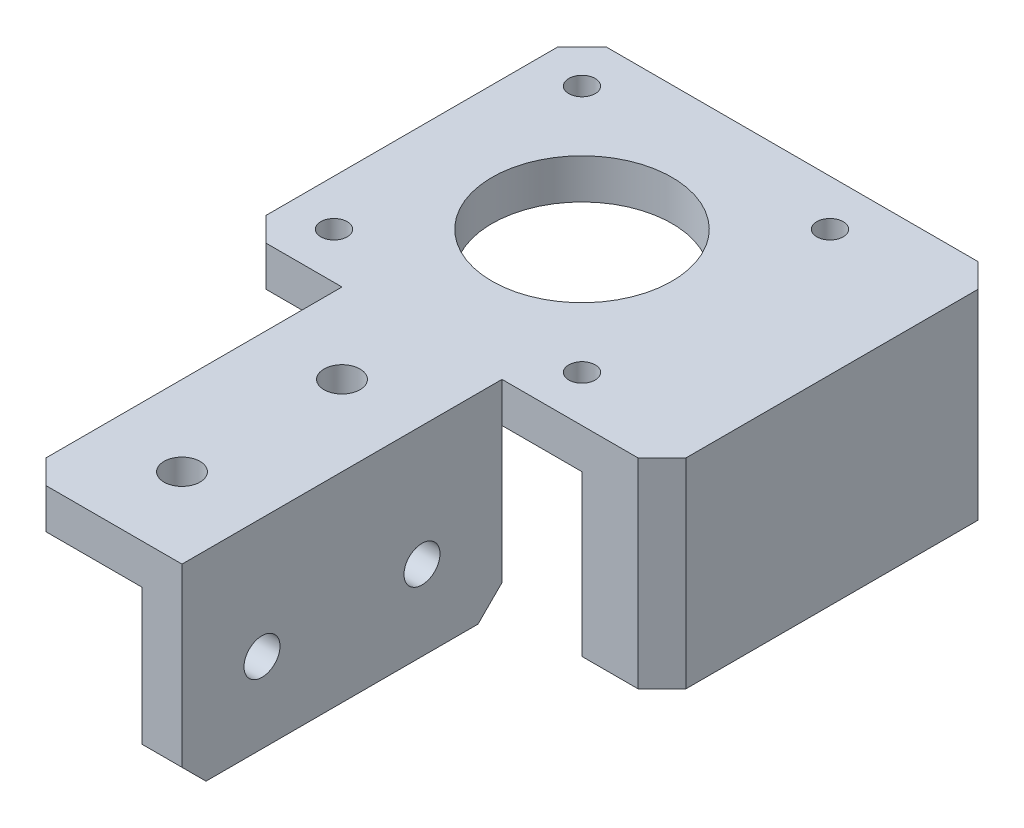
from build123d import *

# Parameters (mm, degrees)
SKETCH1_W           = 42.5
SKETCH1_H           = 42.5
SKETCH1_R           = 11.25
SKETCH1_R_2         = 1.65
BOSS_EXTRUDE1_DEPTH = 5
SKETCH3_W           = 10
SKETCH3_H           = 42.5
SKETCH3_W_2         = 5
SKETCH3_H_2         = 40
BOSS_EXTRUDE2_DEPTH = 25
CHAMFER1_SIZE       = 3
SKETCH5_W           = 40
SKETCH5_H           = 5
BOSS_EXTRUDE3_DEPTH = 15
CUT_EXTRUDE5_REACH  = 27
SKETCH9_R           = 2.25
CUT_EXTRUDE6_REACH  = 27
SKETCH10_R          = 2.25
SKETCH11_R          = 3.75
CUT_EXTRUDE7_DEPTH  = 1
SKETCH12_R          = 3.75
CUT_EXTRUDE8_DEPTH  = 1
CHAMFER2_SIZE       = 3


with BuildPart() as part:
    # Sketch1 → Boss-Extrude1 (new body)
    with BuildSketch(Plane(origin=(0, 0, 0), x_dir=(1, 0, 0), z_dir=(0, 1, 0))):
        Rectangle(SKETCH1_W, SKETCH1_H)
        Circle(SKETCH1_R, mode=Mode.SUBTRACT)
        with Locations((-15.5, 15.5)):
            Circle(SKETCH1_R_2, mode=Mode.SUBTRACT)
        with Locations((15.5, 15.5)):
            Circle(SKETCH1_R_2, mode=Mode.SUBTRACT)
        with Locations((15.5, -15.5)):
            Circle(SKETCH1_R_2, mode=Mode.SUBTRACT)
        with Locations((-15.5, -15.5)):
            Circle(SKETCH1_R_2, mode=Mode.SUBTRACT)
    extrude(amount=BOSS_EXTRUDE1_DEPTH)

    # Sketch3 → Boss-Extrude2 (add)
    with BuildSketch(Plane(origin=(0, 5, 0), x_dir=(1, 0, 0), z_dir=(0, 1, 0))):
        with Locations((26.25, 0)):
            Rectangle(SKETCH3_W, SKETCH3_H)
        with Locations((8.75, -41.25)):
            Rectangle(SKETCH3_W_2, SKETCH3_H_2)
    extrude(amount=-BOSS_EXTRUDE2_DEPTH)

    # Chamfer1
    chamfer1_edges = [part.edges().sort_by_distance(p)[0] for p in [
        (31.25, -7.5, -21.25),
        (31.25, -7.5, 21.25),
        (-21.25, 2.5, 21.25),
        (-21.25, 2.5, -21.25),
    ]]
    chamfer(chamfer1_edges, length=CHAMFER1_SIZE)

    # Sketch5 → Boss-Extrude3 (add)
    with BuildSketch(Plane.ZY.offset(-6.25)):
        with Locations((41.25, 2.5)):
            Rectangle(SKETCH5_W, SKETCH5_H)
    extrude(amount=BOSS_EXTRUDE3_DEPTH)

    # Sketch9 → Cut-Extrude5 (cut, up to next)
    with BuildSketch(Plane(origin=(0, 5, 0), x_dir=(1, 0, 0), z_dir=(0, 1, 0)), mode=Mode.PRIVATE) as cut_extrude5_sk1:
        with Locations((1.25, -51.25)):
            Circle(SKETCH9_R)
    cut_extrude5_tool1 = extrude(cut_extrude5_sk1.sketch, amount=-CUT_EXTRUDE5_REACH, mode=Mode.PRIVATE) & part.part
    add(cut_extrude5_tool1.solids().sort_by_distance((1.25, 5, 51.25))[0], mode=Mode.SUBTRACT)
    # Sketch9 → Cut-Extrude5 (cut, up to next)
    with BuildSketch(Plane(origin=(0, 5, 0), x_dir=(1, 0, 0), z_dir=(0, 1, 0)), mode=Mode.PRIVATE) as cut_extrude5_sk2:
        with Locations((1.25, -31.25)):
            Circle(SKETCH9_R)
    cut_extrude5_tool2 = extrude(cut_extrude5_sk2.sketch, amount=-CUT_EXTRUDE5_REACH, mode=Mode.PRIVATE) & part.part
    add(cut_extrude5_tool2.solids().sort_by_distance((1.25, 5, 31.25))[0], mode=Mode.SUBTRACT)

    # Sketch10 → Cut-Extrude6 (cut, up to next)
    with BuildSketch(Plane.ZY.offset(-6.25), mode=Mode.PRIVATE) as cut_extrude6_sk1:
        with Locations((51.25, -10)):
            Circle(SKETCH10_R)
    cut_extrude6_tool1 = extrude(cut_extrude6_sk1.sketch, amount=-CUT_EXTRUDE6_REACH, mode=Mode.PRIVATE) & part.part
    add(cut_extrude6_tool1.solids().sort_by_distance((6.25, -10, 51.25))[0], mode=Mode.SUBTRACT)
    # Sketch10 → Cut-Extrude6 (cut, up to next)
    with BuildSketch(Plane.ZY.offset(-6.25), mode=Mode.PRIVATE) as cut_extrude6_sk2:
        with Locations((31.25, -10)):
            Circle(SKETCH10_R)
    cut_extrude6_tool2 = extrude(cut_extrude6_sk2.sketch, amount=-CUT_EXTRUDE6_REACH, mode=Mode.PRIVATE) & part.part
    add(cut_extrude6_tool2.solids().sort_by_distance((6.25, -10, 31.25))[0], mode=Mode.SUBTRACT)

    # Sketch11 → Cut-Extrude7 (cut)
    with BuildSketch(Plane.XZ):
        with Locations((1.25, 51.25)):
            Circle(SKETCH11_R)
        with Locations((1.25, 31.25)):
            Circle(SKETCH11_R)
    extrude(amount=-CUT_EXTRUDE7_DEPTH, mode=Mode.SUBTRACT)

    # Sketch12 → Cut-Extrude8 (cut)
    with BuildSketch(Plane.ZY.offset(-6.25)):
        with Locations((31.25, -10)):
            Circle(SKETCH12_R)
        with Locations((51.25, -10)):
            Circle(SKETCH12_R)
    extrude(amount=-CUT_EXTRUDE8_DEPTH, mode=Mode.SUBTRACT)

    # Chamfer2
    chamfer2_edges = [part.edges().sort_by_distance(p)[0] for p in [
        (8.75, -20, 21.25),
        (8.75, -20, 61.25),
        (-8.75, 2.5, 61.25),
    ]]
    chamfer(chamfer2_edges, length=CHAMFER2_SIZE)


solid = part.part
